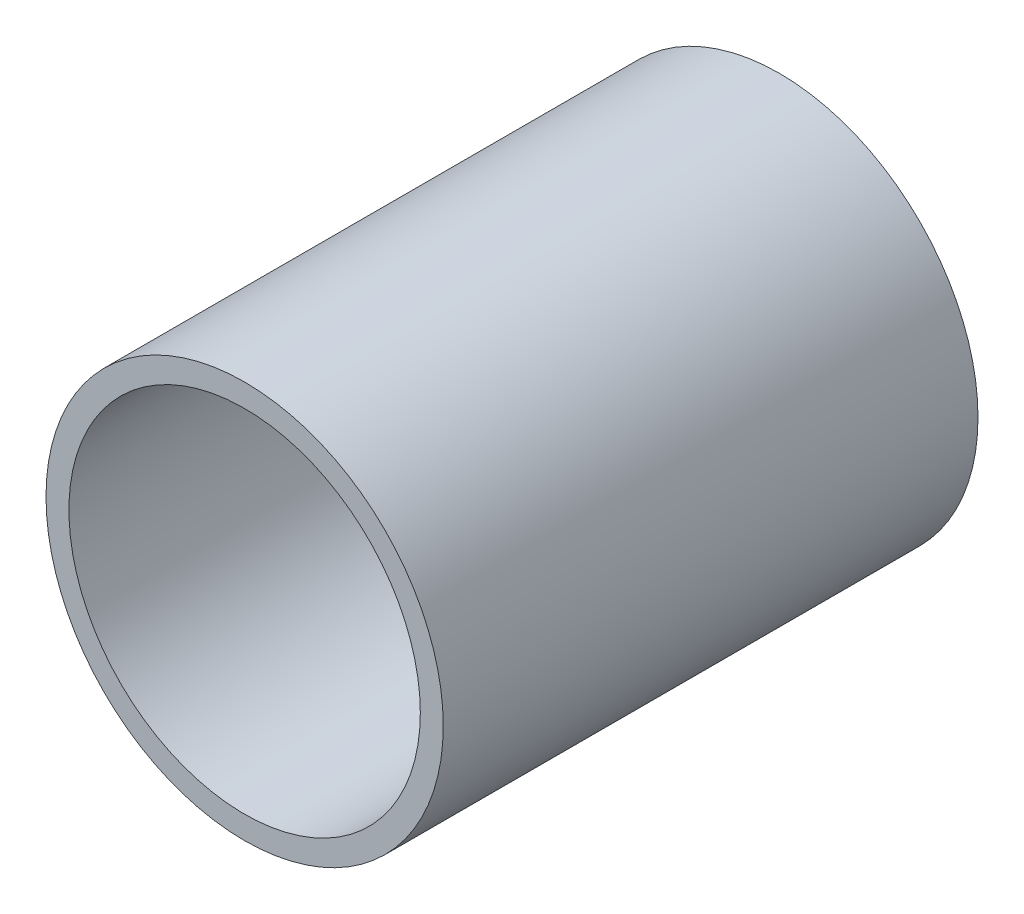
from build123d import *

# Parameters (mm, degrees)
SKETCH2_W = 3
SKETCH2_H = 70


with BuildPart() as part:
    # Sketch2 → Revolve1 (revolve)
    with BuildSketch(Plane(origin=(0, 0, 0), x_dir=(1, 0, 0), z_dir=(0, 1, 0))):
        with Locations((24.5, 35)):
            Rectangle(SKETCH2_W, SKETCH2_H)
    revolve(axis=Axis((0, 0, 0), (0, 0, -1)))


solid = part.part
